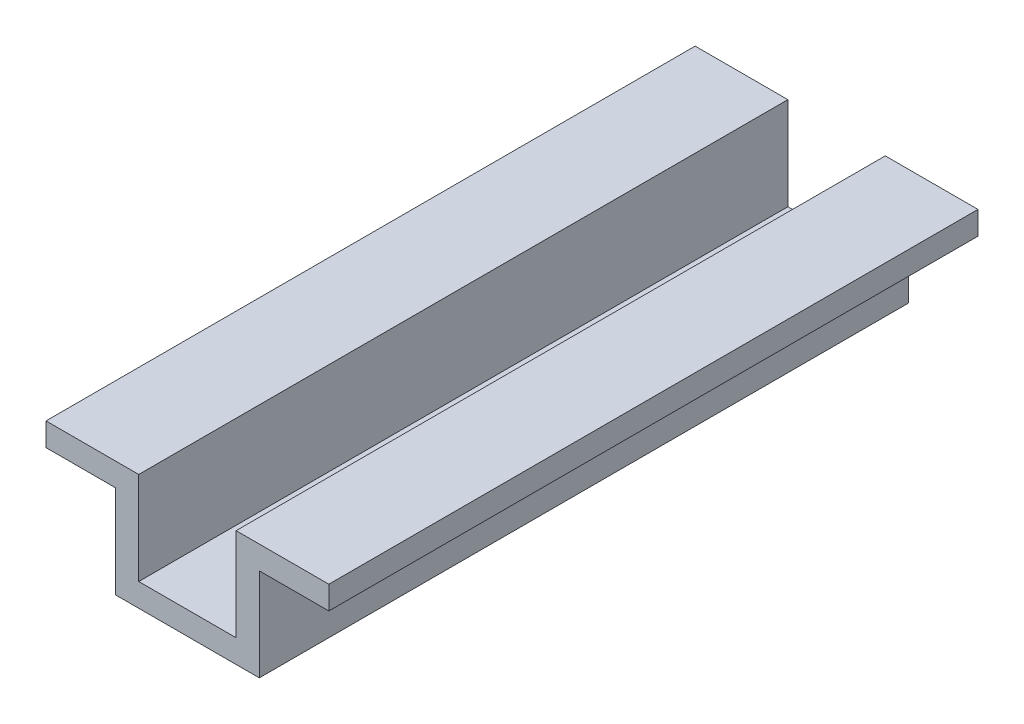
from build123d import *

# Parameters (mm, degrees)
EXTRUDE_THIN1_DEPTH = 140


with BuildPart() as part:
    # Sketch1 → Extrude-Thin1 (new body)
    with BuildSketch(Plane.XY):
        Polygon((-20, 20), (0, 20), (0, 0), (21, 0), (21, 20), (41, 20), (41, 15), (26, 15), (26, -5), (-5, -5), (-5, 15), (-20, 15), align=None)
    extrude(amount=EXTRUDE_THIN1_DEPTH)


solid = part.part
